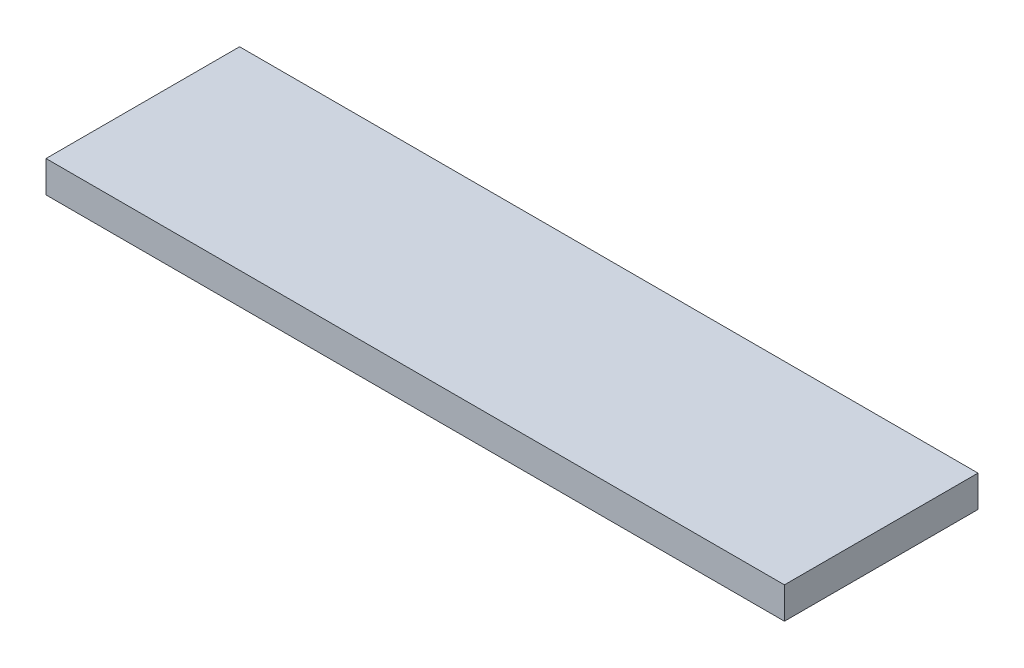
from build123d import *

# Parameters (mm, degrees)
SKETCH_1_W      = 515
SKETCH_1_H      = 135
EXTRUDE_1_DEPTH = 22


with BuildPart() as part:
    # Эскиз1 → Бобышка-Вытянуть1 (new body)
    with BuildSketch(Plane(origin=(0, 0, 0), x_dir=(1, 0, 0), z_dir=(0, 1, 0))):
        Rectangle(SKETCH_1_W, SKETCH_1_H)
    extrude(amount=EXTRUDE_1_DEPTH)


solid = part.part
